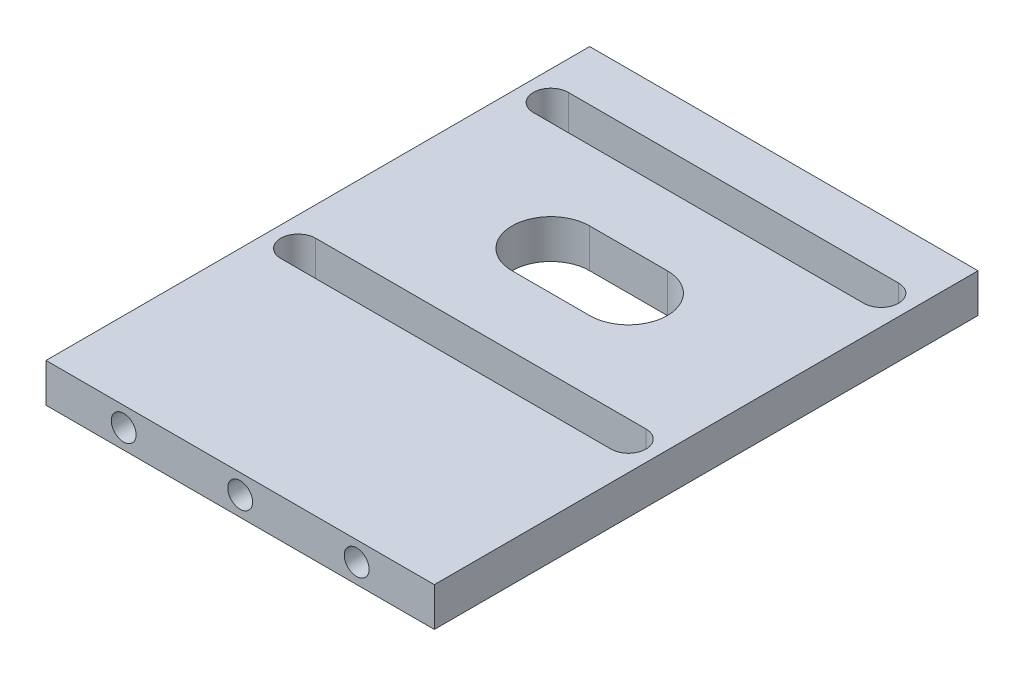
from build123d import *

# Parameters (mm, degrees)
SKETCH1_W           = 50
SKETCH1_H           = 70
BOSS_EXTRUDE1_DEPTH = 5
SKETCH2_R           = 1.6
CUT_EXTRUDE1_DEPTH  = 10


with BuildPart() as part:
    # Sketch1 → Boss-Extrude1 (new body)
    with BuildSketch(Plane(origin=(0, 0, 0), x_dir=(1, 0, 0), z_dir=(0, 1, 0))):
        with Locations((-4.575074469, 3.274395374)):
            Rectangle(SKETCH1_W, SKETCH1_H)
        with BuildLine():
            Line((-25.838530436, 31.787851342), (16.688381499, 31.787851342))
            ThreePointArc((16.688381499, 31.787851342), (18.938381499, 29.537851342), (16.688381499, 27.287851342))
            Line((16.688381499, 27.287851342), (-25.838530436, 27.287851342))
            ThreePointArc((-25.838530436, 27.287851342), (-28.088530436, 29.537851342), (-25.838530436, 31.787851342))
        make_face(mode=Mode.SUBTRACT)
        with BuildLine():
            Line((-9.575074469, 18.274395374), (0.424925531, 18.274395374))
            ThreePointArc((0.424925531, 18.274395374), (5.424925531, 13.274395374), (0.424925531, 8.274395374))
            Line((0.424925531, 8.274395374), (-9.575074469, 8.274395374))
            ThreePointArc((-9.575074469, 8.274395374), (-14.575074469, 13.274395374), (-9.575074469, 18.274395374))
        make_face(mode=Mode.SUBTRACT)
        with BuildLine():
            Line((-25.838530436, -5.239060593), (16.688381499, -5.239060593))
            ThreePointArc((16.688381499, -5.239060593), (18.938381499, -2.989060593), (16.688381499, -0.739060593))
            Line((16.688381499, -0.739060593), (-25.838530436, -0.739060593))
            ThreePointArc((-25.838530436, -0.739060593), (-28.088530436, -2.989060593), (-25.838530436, -5.239060593))
        make_face(mode=Mode.SUBTRACT)
    extrude(amount=BOSS_EXTRUDE1_DEPTH)

    # Sketch2 → Cut-Extrude1 (cut)
    with BuildSketch(Plane.XY.offset(31.725604626)):
        with Locations((-4.575074469, 2.5)):
            Circle(SKETCH2_R)
        with Locations((-19.575074469, 2.5)):
            Circle(SKETCH2_R)
        with Locations((10.424925531, 2.5)):
            Circle(SKETCH2_R)
    extrude(amount=-CUT_EXTRUDE1_DEPTH, mode=Mode.SUBTRACT)


solid = part.part
